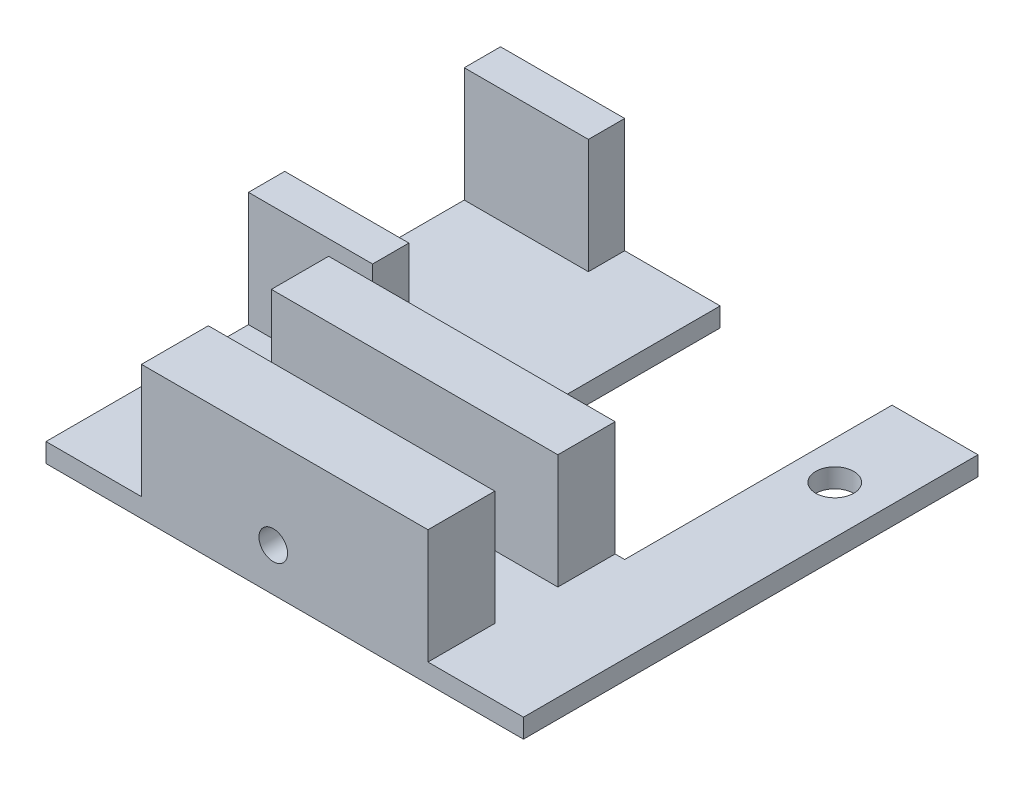
from build123d import *

# Parameters (mm, degrees)
SKETCH1_W                  = 63.5
SKETCH1_H                  = 60.452
BOSS_EXTRUDE1_DEPTH        = 1.27
SKETCH2_W                  = 16.51
SKETCH2_H                  = 4.826
SKETCH2_W_2                = 38.1
SKETCH2_H_2                = 8.89
SKETCH2_H_3                = 7.62
BOSS_EXTRUDE2_DEPTH        = 15.24
SKETCH3_R                  = 1.905
CUT_EXTRUDE1_DEPTH         = 25.892
SKETCH4_R                  = 3.175
CUT_EXTRUDE2_DEPTH         = 7.62
SKETCH5_W                  = 22.86
SKETCH5_H                  = 24.252018656
SKETCH5_H_2                = 1.10530733
SKETCH5_H_3                = 10.202674014
CUT_EXTRUDE3_DEPTH         = 18.78
F_8_0_199_DIAMETER_HOLE1_D = 5.0546


with BuildPart() as part:
    # Sketch1 → Boss-Extrude1 (new body, symmetric)
    with BuildSketch(Plane(origin=(0, 0, 0), x_dir=(1, 0, 0), z_dir=(0, 1, 0))):
        Rectangle(SKETCH1_W, SKETCH1_H)
    extrude(amount=BOSS_EXTRUDE1_DEPTH, both=True)

    # Sketch2 → Boss-Extrude2 (add)
    with BuildSketch(Plane(origin=(0, 1.27, 0), x_dir=(1, 0, 0), z_dir=(0, 1, 0))):
        with Locations((-23.495, 27.813)):
            Rectangle(SKETCH2_W, SKETCH2_H)
        with Locations((-23.495, -0.889)):
            Rectangle(SKETCH2_W, SKETCH2_H)
        with Locations((0, -25.781)):
            Rectangle(SKETCH2_W_2, SKETCH2_H_2)
        with Locations((0, -9.144)):
            Rectangle(SKETCH2_W_2, SKETCH2_H_3)
    extrude(amount=BOSS_EXTRUDE2_DEPTH)

    # Sketch3 → Cut-Extrude1 (cut, through all)
    with BuildSketch(Plane(origin=(0, 0, 5.334), x_dir=(-1, 0, 0), z_dir=(0, 0, -1))):
        with Locations((1.524, 4.445)):
            Circle(SKETCH3_R)
    extrude(amount=-CUT_EXTRUDE1_DEPTH, mode=Mode.SUBTRACT)

    # Sketch4 → Cut-Extrude2 (cut)
    with BuildSketch(Plane(origin=(0, 0, 5.334), x_dir=(-1, 0, 0), z_dir=(0, 0, -1))):
        with Locations((1.524, 4.445)):
            Circle(SKETCH4_R)
    extrude(amount=-CUT_EXTRUDE2_DEPTH, mode=Mode.SUBTRACT)

    # Sketch5 → Cut-Extrude3 (cut, through all)
    with BuildSketch(Plane.XZ.offset(1.27)):
        with Locations((8.89, -16.994683342)):
            Rectangle(SKETCH5_W, SKETCH5_H)
        with Locations((8.89, -29.673346335)):
            Rectangle(SKETCH5_W, SKETCH5_H_2)
        with Locations((8.89, 0.232662993)):
            Rectangle(SKETCH5_W, SKETCH5_H_3)
    extrude(amount=-CUT_EXTRUDE3_DEPTH, mode=Mode.SUBTRACT)

    # #8 (0.199) Diameter Hole1 (through all)
    with Locations(Plane(origin=(-6.35, 1.27, 1.524), x_dir=(0, 0, 1), z_dir=(0, 1, 0))):
        with Locations((0, 0), (15.875, -12.7), (-19.05, 31.75)):
            Hole(F_8_0_199_DIAMETER_HOLE1_D / 2)


solid = part.part
